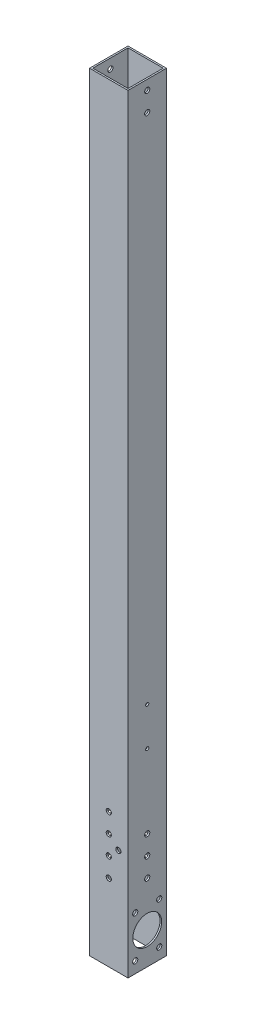
from build123d import *

# Parameters (mm, degrees)
SKETCH1_W           = 38.1
SKETCH1_H           = 38.1
SKETCH1_W_2         = 34.925
SKETCH1_H_2         = 34.925
BOSS_EXTRUDE1_DEPTH = 762
SKETCH2_R           = 2.5527
CUT_EXTRUDE1_DEPTH  = 39.1
SKETCH3_R           = 2.5527
SKETCH3_R_2         = 1.5875
CUT_EXTRUDE2_DEPTH  = 39.1
SKETCH4_R           = 14.2875
SKETCH4_R_2         = 2.5527
CUT_EXTRUDE3_DEPTH  = 39.1


with BuildPart() as part:
    # Sketch1 → Boss-Extrude1 (new body)
    with BuildSketch(Plane(origin=(0, 0, 0), x_dir=(1, 0, 0), z_dir=(0, 1, 0))):
        Rectangle(SKETCH1_W, SKETCH1_H)
        Rectangle(SKETCH1_W_2, SKETCH1_H_2, mode=Mode.SUBTRACT)
    extrude(amount=BOSS_EXTRUDE1_DEPTH)

    # Sketch2 → Cut-Extrude1 (cut, through all)
    with BuildSketch(Plane.XY.offset(19.05)):
        with Locations((0, 76.2)):
            Circle(SKETCH2_R)
        with Locations((0, 95.25)):
            Circle(SKETCH2_R)
        with Locations((0, 114.3)):
            Circle(SKETCH2_R)
        with Locations((0, 133.35)):
            Circle(SKETCH2_R)
        with Locations((9.525, 104.775)):
            Circle(SKETCH2_R)
    extrude(amount=-CUT_EXTRUDE1_DEPTH, mode=Mode.SUBTRACT)

    # Sketch3 → Cut-Extrude2 (cut, through all)
    with BuildSketch(Plane(origin=(19.05, 0, 0), x_dir=(0, 0, -1), z_dir=(1, 0, 0))):
        with Locations((0, 76.2)):
            Circle(SKETCH3_R)
        with Locations((0, 95.25)):
            Circle(SKETCH3_R)
        with Locations((0, 114.3)):
            Circle(SKETCH3_R)
        with Locations((0, 225.425)):
            Circle(SKETCH3_R_2)
        with Locations((0, 187.325)):
            Circle(SKETCH3_R_2)
        with Locations((0, 752.475)):
            Circle(SKETCH3_R)
        with Locations((0, 733.425)):
            Circle(SKETCH3_R)
    extrude(amount=-CUT_EXTRUDE2_DEPTH, mode=Mode.SUBTRACT)

    # Sketch4 → Cut-Extrude3 (cut, through all)
    with BuildSketch(Plane(origin=(19.05, 0, 0), x_dir=(0, 0, -1), z_dir=(1, 0, 0))):
        with Locations((0, 31.75)):
            Circle(SKETCH4_R)
        with Locations((-11.90625, 52.372229928)):
            Circle(SKETCH4_R_2)
        with Locations((11.90625, 52.372229928)):
            Circle(SKETCH4_R_2)
        with Locations((11.90625, 11.127770072)):
            Circle(SKETCH4_R_2)
        with Locations((-11.90625, 11.127770072)):
            Circle(SKETCH4_R_2)
    extrude(amount=-CUT_EXTRUDE3_DEPTH, mode=Mode.SUBTRACT)


solid = part.part
